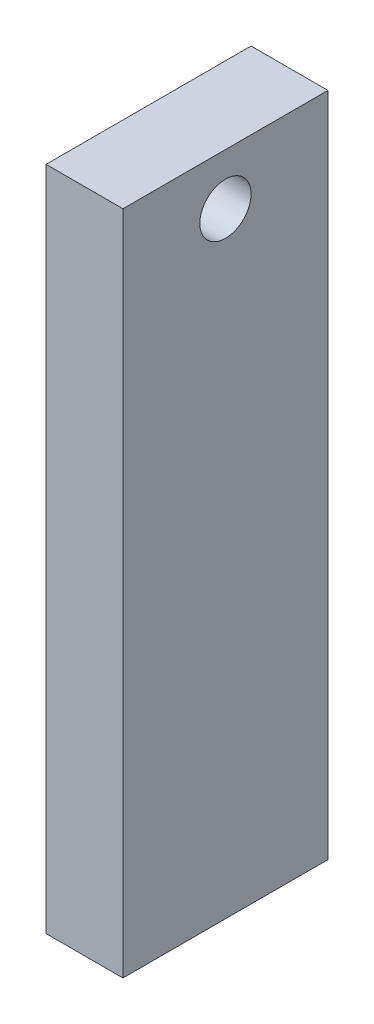
from build123d import *

# Parameters (mm, degrees)
SKETCH1_W           = 50.8
SKETCH1_H           = 165.1
SKETCH1_R           = 6.35
BOSS_EXTRUDE1_DEPTH = 19.05


with BuildPart() as part:
    # Sketch1 → Boss-Extrude1 (new body)
    with BuildSketch(Plane(origin=(0, 0, 0), x_dir=(0, 0, -1), z_dir=(1, 0, 0))):
        with Locations((25.4, 82.55)):
            Rectangle(SKETCH1_W, SKETCH1_H)
        with Locations((25.4, 152.4)):
            Circle(SKETCH1_R, mode=Mode.SUBTRACT)
    extrude(amount=BOSS_EXTRUDE1_DEPTH)


solid = part.part
